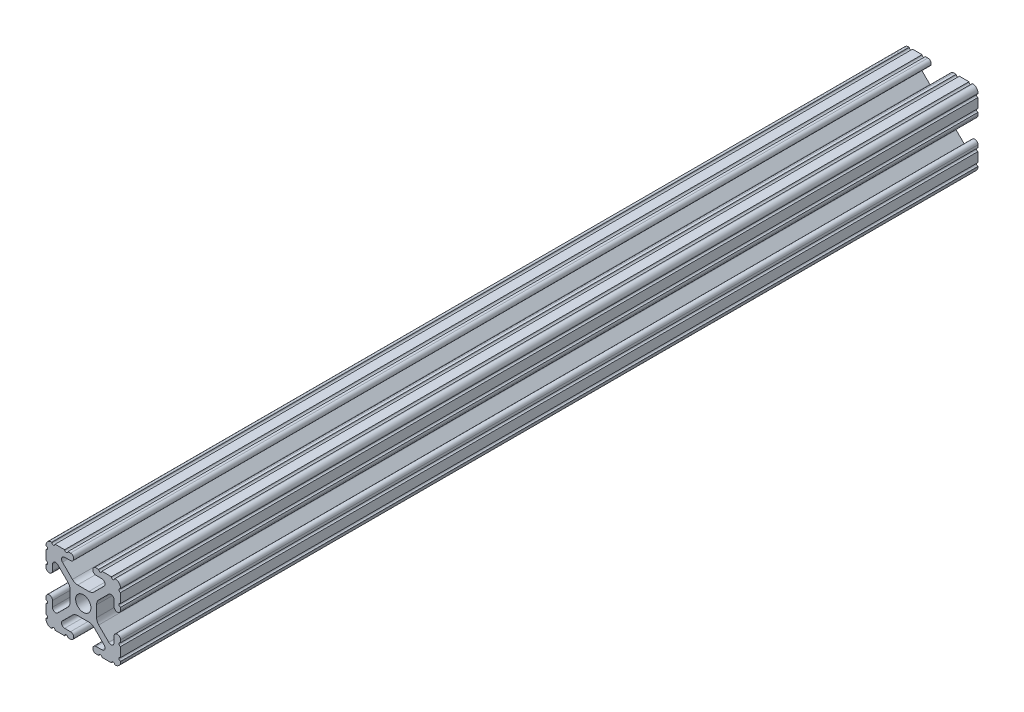
from build123d import *

# Parameters (mm, degrees)
SKETCH3_W                = 25.4
SKETCH3_H                = 25.4
BOSS_EXTRUDE1_DEPTH      = 146.05
BOSS_EXTRUDE1_DEPTH_BACK = 146.05
SKETCH4_R                = 2.6035
CUT_EXTRUDE1_DEPTH       = 293.1
CUT_EXTRUDE2_DEPTH       = 293.1
FILLET1_R                = 2.54
FILLET2_R                = 1.778


with BuildPart() as part:
    # Sketch3 → Boss-Extrude1 (new body, two sides)
    with BuildSketch(Plane.XY) as boss_extrude1_sk:
        Rectangle(SKETCH3_W, SKETCH3_H)
    extrude(amount=BOSS_EXTRUDE1_DEPTH)
    extrude(boss_extrude1_sk.sketch, amount=-BOSS_EXTRUDE1_DEPTH_BACK)

    # Sketch4 → Cut-Extrude1 (cut, through all)
    with BuildSketch(Plane.XY.offset(146.05)):
        with BuildLine():
            Line((3.2512, 12.7), (-3.2512, 12.7))
            Line((-3.2512, 12.7), (-3.2512, 10.4902))
            Line((-3.2512, 10.4902), (-6.348478019, 10.4902))
            ThreePointArc((-6.348478019, 10.4902), (-7.335478831, 9.830707141), (-7.103895736, 8.666460301))
            Line((-7.103895736, 8.666460301), (-2.958635435, 4.5212))
            Line((-2.958635435, 4.5212), (2.958635435, 4.5212))
            Line((2.958635435, 4.5212), (7.103895736, 8.666460301))
            ThreePointArc((7.103895736, 8.666460301), (7.335478831, 9.830707141), (6.348478019, 10.4902))
            Line((6.348478019, 10.4902), (3.2512, 10.4902))
            Line((3.2512, 10.4902), (3.2512, 12.7))
        make_face()
        with BuildLine():
            Line((12.7, -3.2512), (12.7, 3.2512))
            Line((12.7, 3.2512), (10.4902, 3.2512))
            Line((10.4902, 3.2512), (10.4902, 6.348478019))
            ThreePointArc((10.4902, 6.348478019), (9.830707141, 7.335478831), (8.666460301, 7.103895736))
            Line((8.666460301, 7.103895736), (4.5212, 2.958635435))
            Line((4.5212, 2.958635435), (4.5212, -2.958635435))
            Line((4.5212, -2.958635435), (8.666460301, -7.103895736))
            ThreePointArc((8.666460301, -7.103895736), (9.830707141, -7.335478831), (10.4902, -6.348478019))
            Line((10.4902, -6.348478019), (10.4902, -3.2512))
            Line((10.4902, -3.2512), (12.7, -3.2512))
        make_face()
        with BuildLine():
            Line((-3.2512, -10.4902), (-3.2512, -12.7))
            Line((-3.2512, -12.7), (3.2512, -12.7))
            Line((3.2512, -12.7), (3.2512, -10.4902))
            Line((3.2512, -10.4902), (6.348478019, -10.4902))
            ThreePointArc((6.348478019, -10.4902), (7.335478831, -9.830707141), (7.103895736, -8.666460301))
            Line((7.103895736, -8.666460301), (2.958635435, -4.5212))
            Line((2.958635435, -4.5212), (-2.958635435, -4.5212))
            Line((-2.958635435, -4.5212), (-7.103895736, -8.666460301))
            ThreePointArc((-7.103895736, -8.666460301), (-7.335478831, -9.830707141), (-6.348478019, -10.4902))
            Line((-6.348478019, -10.4902), (-3.2512, -10.4902))
        make_face()
        with BuildLine():
            Line((-10.4902, 3.2512), (-12.7, 3.2512))
            Line((-12.7, 3.2512), (-12.7, -3.2512))
            Line((-12.7, -3.2512), (-10.4902, -3.2512))
            Line((-10.4902, -3.2512), (-10.4902, -6.348478019))
            ThreePointArc((-10.4902, -6.348478019), (-9.830707141, -7.335478831), (-8.666460301, -7.103895736))
            Line((-8.666460301, -7.103895736), (-4.5212, -2.958635435))
            Line((-4.5212, -2.958635435), (-4.5212, 2.958635435))
            Line((-4.5212, 2.958635435), (-8.666460301, 7.103895736))
            ThreePointArc((-8.666460301, 7.103895736), (-9.830707141, 7.335478831), (-10.4902, 6.348478019))
            Line((-10.4902, 6.348478019), (-10.4902, 3.2512))
        make_face()
        Circle(SKETCH4_R)
    extrude(amount=-CUT_EXTRUDE1_DEPTH, mode=Mode.SUBTRACT)

    # Sketch5 → Cut-Extrude2 (cut, through all)
    with BuildSketch(Plane.XY.offset(146.05)):
        with BuildLine():
            ThreePointArc((-11.5951, 3.2512), (-12.376382283, 3.574817717), (-12.7, 4.3561))
            Line((-12.7, 4.3561), (-12.7, 3.2512))
            Line((-12.7, 3.2512), (-11.5951, 3.2512))
        make_face()
        with BuildLine():
            ThreePointArc((-10.4902, 4.3561), (-10.813817717, 3.574817717), (-11.5951, 3.2512))
            Line((-11.5951, 3.2512), (-10.4902, 3.2512))
            Line((-10.4902, 3.2512), (-10.4902, 4.3561))
        make_face()
        with BuildLine():
            Line((-12.7, -3.2512), (-12.7, -4.3561))
            ThreePointArc((-12.7, -4.3561), (-12.376382283, -3.574817717), (-11.5951, -3.2512))
            Line((-11.5951, -3.2512), (-12.7, -3.2512))
        make_face()
        with BuildLine():
            Line((-10.4902, -3.2512), (-11.5951, -3.2512))
            ThreePointArc((-11.5951, -3.2512), (-10.813817717, -3.574817717), (-10.4902, -4.3561))
            Line((-10.4902, -4.3561), (-10.4902, -3.2512))
        make_face()
        with BuildLine():
            Line((-3.2512, -11.595100007), (-3.2512, -10.4902))
            Line((-3.2512, -10.4902), (-4.3561, -10.4902))
            ThreePointArc((-4.3561, -10.4902), (-3.574817715, -10.81381772), (-3.2512, -11.595100007))
        make_face()
        with BuildLine():
            Line((-3.2512, -12.7), (-3.2512, -11.595100007))
            ThreePointArc((-3.2512, -11.595100007), (-3.57481772, -12.376382285), (-4.3561, -12.7))
            Line((-4.3561, -12.7), (-3.2512, -12.7))
        make_face()
        with BuildLine():
            Line((3.2512, -10.4902), (3.2512, -11.5951))
            ThreePointArc((3.2512, -11.5951), (3.574817718, -10.813817717), (4.3561, -10.4902))
            Line((4.3561, -10.4902), (3.2512, -10.4902))
        make_face()
        with BuildLine():
            Line((3.2512, -12.7), (4.3561, -12.7))
            ThreePointArc((4.3561, -12.7), (3.574817717, -12.376382282), (3.2512, -11.5951))
            Line((3.2512, -11.5951), (3.2512, -12.7))
        make_face()
        with BuildLine():
            Line((11.5951, -3.2512), (10.4902, -3.2512))
            Line((10.4902, -3.2512), (10.4902, -4.3561))
            ThreePointArc((10.4902, -4.3561), (10.813817717, -3.574817717), (11.5951, -3.2512))
        make_face()
        with BuildLine():
            Line((12.7, -3.2512), (11.5951, -3.2512))
            ThreePointArc((11.5951, -3.2512), (12.376382283, -3.574817717), (12.7, -4.3561))
            Line((12.7, -4.3561), (12.7, -3.2512))
        make_face()
        with BuildLine():
            Line((10.4902, 3.2512), (11.5951, 3.2512))
            ThreePointArc((11.5951, 3.2512), (10.813817717, 3.574817717), (10.4902, 4.3561))
            Line((10.4902, 4.3561), (10.4902, 3.2512))
        make_face()
        with BuildLine():
            Line((12.7, 3.2512), (12.7, 4.3561))
            ThreePointArc((12.7, 4.3561), (12.376382283, 3.574817717), (11.5951, 3.2512))
            Line((11.5951, 3.2512), (12.7, 3.2512))
        make_face()
        with BuildLine():
            Line((3.2512, 12.7), (3.2512, 11.595099996))
            ThreePointArc((3.2512, 11.595099996), (3.574817716, 12.376382281), (4.3561, 12.7))
            Line((4.3561, 12.7), (3.2512, 12.7))
        make_face()
        with BuildLine():
            Line((3.2512, 11.595099996), (3.2512, 10.4902))
            Line((3.2512, 10.4902), (4.3561, 10.4902))
            ThreePointArc((4.3561, 10.4902), (3.574817719, 10.813817716), (3.2512, 11.595099996))
        make_face()
        with BuildLine():
            Line((-3.2512, 12.7), (-4.3561, 12.7))
            ThreePointArc((-4.3561, 12.7), (-3.574817717, 12.376382283), (-3.2512, 11.5951))
            Line((-3.2512, 11.5951), (-3.2512, 12.7))
        make_face()
        with BuildLine():
            Line((-3.2512, 10.4902), (-3.2512, 11.5951))
            ThreePointArc((-3.2512, 11.5951), (-3.574817717, 10.813817717), (-4.3561, 10.4902))
            Line((-4.3561, 10.4902), (-3.2512, 10.4902))
        make_face()
        with BuildLine():
            ThreePointArc((-12.7, 5.23875), (-12.14755, 5.7912), (-12.7, 6.34365))
            Line((-12.7, 6.34365), (-12.7, 5.23875))
        make_face()
        with BuildLine():
            ThreePointArc((-12.7, 9.60755), (-12.14755, 10.16), (-12.7, 10.71245))
            Line((-12.7, 10.71245), (-12.7, 9.60755))
        make_face()
        with BuildLine():
            ThreePointArc((-10.71245, 12.7), (-10.16, 12.14755), (-9.60755, 12.7))
            Line((-9.60755, 12.7), (-10.71245, 12.7))
        make_face()
        with BuildLine():
            ThreePointArc((-6.34365, 12.7), (-5.7912, 12.14755), (-5.23875, 12.7))
            Line((-5.23875, 12.7), (-6.34365, 12.7))
        make_face()
        with BuildLine():
            Line((6.34365, 12.7), (5.23875, 12.7))
            ThreePointArc((5.23875, 12.7), (5.7912, 12.14755), (6.34365, 12.7))
        make_face()
        with BuildLine():
            Line((10.71245, 12.7), (9.60755, 12.7))
            ThreePointArc((9.60755, 12.7), (10.16, 12.14755), (10.71245, 12.7))
        make_face()
        with BuildLine():
            Line((12.7, 10.71245), (12.7, 9.60755))
            ThreePointArc((12.7, 9.60755), (12.14755, 10.16), (12.7, 10.71245))
        make_face()
        with BuildLine():
            Line((12.7, 6.34365), (12.7, 5.23875))
            ThreePointArc((12.7, 5.23875), (12.14755, 5.7912), (12.7, 6.34365))
        make_face()
        with BuildLine():
            Line((-12.7, -6.34365), (-12.7, -5.23875))
            ThreePointArc((-12.7, -5.23875), (-12.14755, -5.7912), (-12.7, -6.34365))
        make_face()
        with BuildLine():
            Line((-12.7, -10.71245), (-12.7, -9.60755))
            ThreePointArc((-12.7, -9.60755), (-12.14755, -10.16), (-12.7, -10.71245))
        make_face()
        with BuildLine():
            Line((-10.71245, -12.7), (-9.60755, -12.7))
            ThreePointArc((-9.60755, -12.7), (-10.16, -12.14755), (-10.71245, -12.7))
        make_face()
        with BuildLine():
            Line((-6.34365, -12.7), (-5.23875, -12.7))
            ThreePointArc((-5.23875, -12.7), (-5.7912, -12.14755), (-6.34365, -12.7))
        make_face()
        with BuildLine():
            Line((12.7, -10.71245), (12.7, -9.60755))
            ThreePointArc((12.7, -9.60755), (12.14755, -10.16), (12.7, -10.71245))
        make_face()
        with BuildLine():
            Line((12.7, -6.34365), (12.7, -5.23875))
            ThreePointArc((12.7, -5.23875), (12.14755, -5.7912), (12.7, -6.34365))
        make_face()
        with BuildLine():
            Line((10.71245, -12.7), (9.60755, -12.7))
            ThreePointArc((9.60755, -12.7), (10.16, -12.14755), (10.71245, -12.7))
        make_face()
        with BuildLine():
            Line((6.34365, -12.7), (5.23875, -12.7))
            ThreePointArc((5.23875, -12.7), (5.7912, -12.14755), (6.34365, -12.7))
        make_face()
    extrude(amount=-CUT_EXTRUDE2_DEPTH, mode=Mode.SUBTRACT)

    # Fillet1
    fillet1_edges = [part.edges().sort_by_distance(p)[0] for p in [
        (2.958635435, 4.5212, 0),
        (-2.958635435, 4.5212, 0),
        (-2.958635435, -4.5212, 0),
        (2.958635435, -4.5212, 0),
        (4.5212, -2.958635435, 0),
        (4.5212, 2.958635435, 0),
        (-4.5212, 2.958635435, 0),
        (-4.5212, -2.958635435, 0),
    ]]
    fillet(fillet1_edges, radius=FILLET1_R)

    # Fillet2
    fillet2_edges = [part.edges().sort_by_distance(p)[0] for p in [
        (-12.7, 12.7, 0),
        (12.7, 12.7, 0),
        (12.7, -12.7, 0),
        (-12.7, -12.7, 0),
    ]]
    fillet(fillet2_edges, radius=FILLET2_R)


solid = part.part
